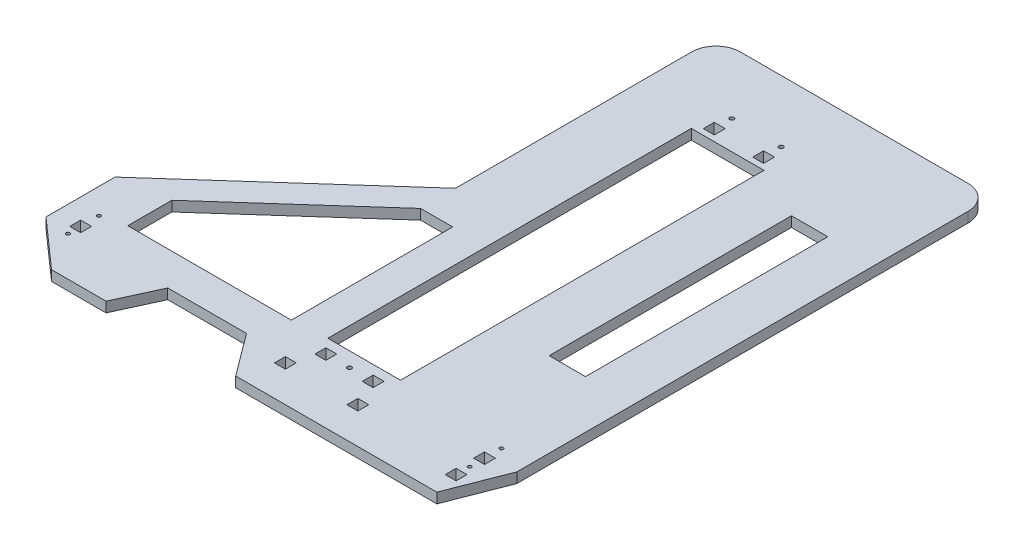
from build123d import *

# Parameters (mm, degrees)
BOSS_EXTRUDE1_DEPTH = 8.4
SKETCH2_R           = 1.5
SKETCH2_R_2         = 1.75
SKETCH2_W           = 60
SKETCH2_H           = 300
SKETCH2_W_2         = 9
SKETCH2_H_2         = 9
CUT_EXTRUDE1_DEPTH  = 9.4
FILLET1_R           = 20
SKETCH4_W           = 30
SKETCH4_H           = 200
CUT_EXTRUDE3_DEPTH  = 9.4


with BuildPart() as part:
    # Sketch1 → Boss-Extrude1 (new body)
    with BuildSketch(Plane(origin=(0, 0, 0), x_dir=(1, 0, 0), z_dir=(0, 1, 0))):
        Polygon((0, 0), (-228, 0), (-228, -215), (-376.5, -347.47169509), (-376.5, -404.47169509), (-336.5, -439.9), (-291.5, -439.9), (-275.5, -405), (-210.5, -405), (-184.5, -439.9), (-18.5, -439.9), (0, -392.4), align=None)
    extrude(amount=BOSS_EXTRUDE1_DEPTH)

    # Sketch2 → Cut-Extrude1 (cut, through all)
    with BuildSketch(Plane(origin=(0, 8.4, 0), x_dir=(1, 0, 0), z_dir=(0, 1, 0))):
        with Locations((-23.1, -408.2)):
            Circle(SKETCH2_R)
        with Locations((-23.1, -382)):
            Circle(SKETCH2_R)
        with Locations((-355.4, -407.37169509)):
            Circle(SKETCH2_R)
        with Locations((-355.4, -381.77169509)):
            Circle(SKETCH2_R)
        with Locations((-163.85, -51.1)):
            Circle(SKETCH2_R_2)
        with Locations((-123.15, -51.1)):
            Circle(SKETCH2_R_2)
        with Locations((-143.5, -387)):
            Circle(SKETCH2_R_2)
        Polygon((-336.5, -340.600531429), (-228, -243.811447811), (-201.5, -243.811447811), (-201.5, -377), (-336.5, -377), align=None)
        with Locations((-143.5, -224.9)):
            Rectangle(SKETCH2_W, SKETCH2_H)
        with Locations((-23.1, -419.4)):
            Rectangle(SKETCH2_W_2, SKETCH2_H_2)
        with Locations((-23.1, -395.95)):
            Rectangle(SKETCH2_W_2, SKETCH2_H_2)
        with Locations((-355.4, -396.97169509)):
            Rectangle(SKETCH2_W_2, SKETCH2_H_2)
        with Locations((-163.85, -65.6)):
            Rectangle(SKETCH2_W_2, SKETCH2_H_2)
        with Locations((-123.15, -65.6)):
            Rectangle(SKETCH2_W_2, SKETCH2_H_2)
        with Locations((-163, -387)):
            Rectangle(SKETCH2_W_2, SKETCH2_H_2)
        with Locations((-124, -387)):
            Rectangle(SKETCH2_W_2, SKETCH2_H_2)
        with Locations((-173.4, -410)):
            Rectangle(SKETCH2_W_2, SKETCH2_H_2)
        with Locations((-113.6, -410)):
            Rectangle(SKETCH2_W_2, SKETCH2_H_2)
    extrude(amount=-CUT_EXTRUDE1_DEPTH, mode=Mode.SUBTRACT)

    # Fillet1
    fillet1_edges = [part.edges().sort_by_distance(p)[0] for p in [
        (-228, 4.2, 0),
        (0, 4.2, 0),
    ]]
    fillet(fillet1_edges, radius=FILLET1_R)

    # Sketch4 → Cut-Extrude3 (cut, through all)
    with BuildSketch(Plane(origin=(0, 8.4, 0), x_dir=(1, 0, 0), z_dir=(0, 1, 0))):
        with Locations((-54.735091888, -195.993725651)):
            Rectangle(SKETCH4_W, SKETCH4_H)
    extrude(amount=-CUT_EXTRUDE3_DEPTH, mode=Mode.SUBTRACT)


solid = part.part
